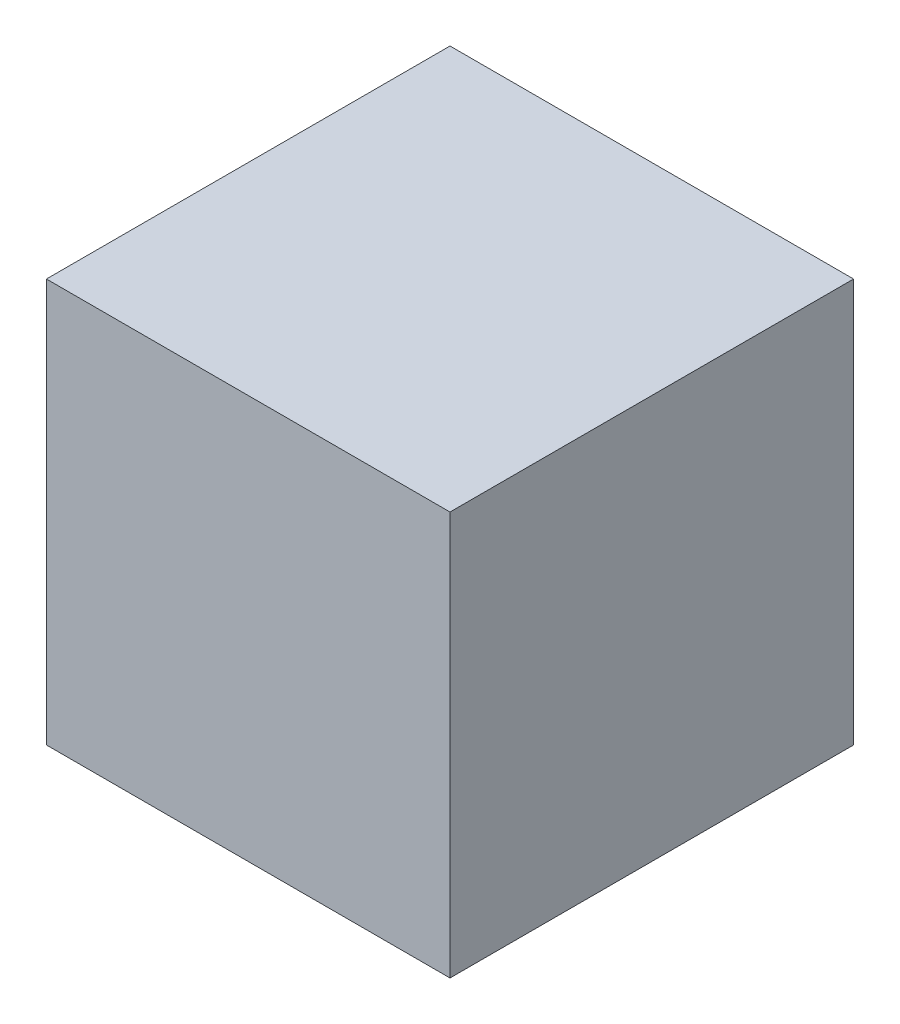
from build123d import *

# Parameters (mm, degrees)
SKETCH1_W           = 60
SKETCH1_H           = 60
BOSS_EXTRUDE1_DEPTH = 60


with BuildPart() as part:
    # Sketch1 → Boss-Extrude1 (new body)
    with BuildSketch(Plane.XY):
        with Locations((30, 30)):
            Rectangle(SKETCH1_W, SKETCH1_H)
    extrude(amount=BOSS_EXTRUDE1_DEPTH)


solid = part.part
